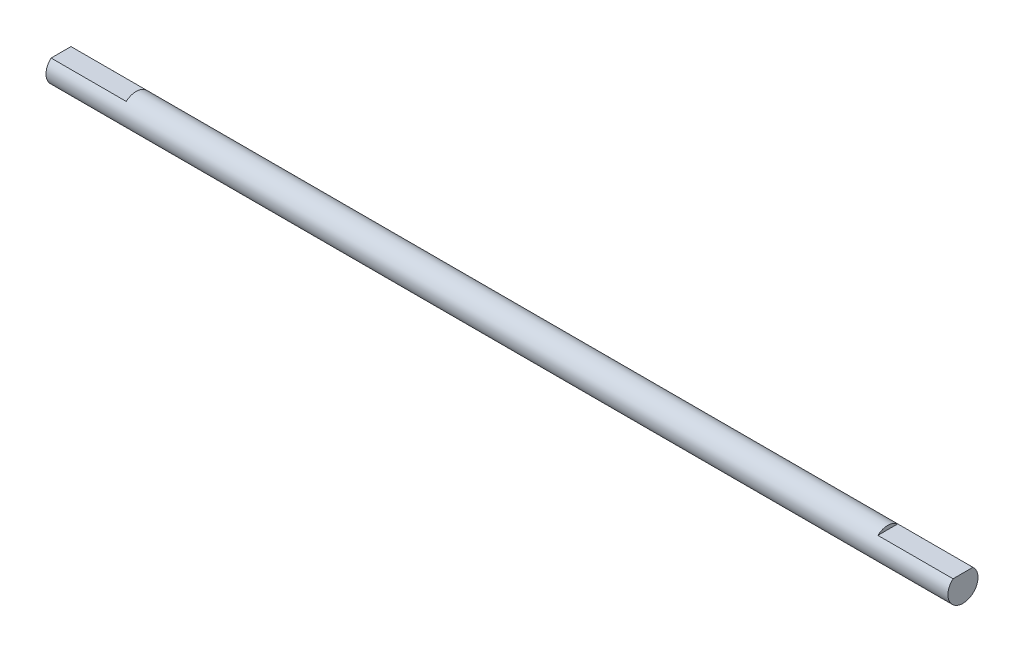
from build123d import *

# Parameters (mm, degrees)
BOSS_EXTRUDE1_DEPTH = 60
SKETCH2_R           = 2
BOSS_EXTRUDE2_DEPTH = 50


with BuildPart() as part:
    # Sketch1 → Boss-Extrude1 (new body, symmetric)
    with BuildSketch(Plane(origin=(0, 0, 0), x_dir=(0, 0, -1), z_dir=(1, 0, 0))):
        with BuildLine():
            Line((-1.322875656, 1.5), (1.322875656, 1.5))
            ThreePointArc((1.322875656, 1.5), (0, -2), (-1.322875656, 1.5))
        make_face()
    extrude(amount=BOSS_EXTRUDE1_DEPTH, both=True)

    # Sketch2 → Boss-Extrude2 (add, symmetric)
    with BuildSketch(Plane(origin=(0, 0, 0), x_dir=(0, 0, -1), z_dir=(1, 0, 0))):
        Circle(SKETCH2_R)
    extrude(amount=BOSS_EXTRUDE2_DEPTH, both=True)


solid = part.part
